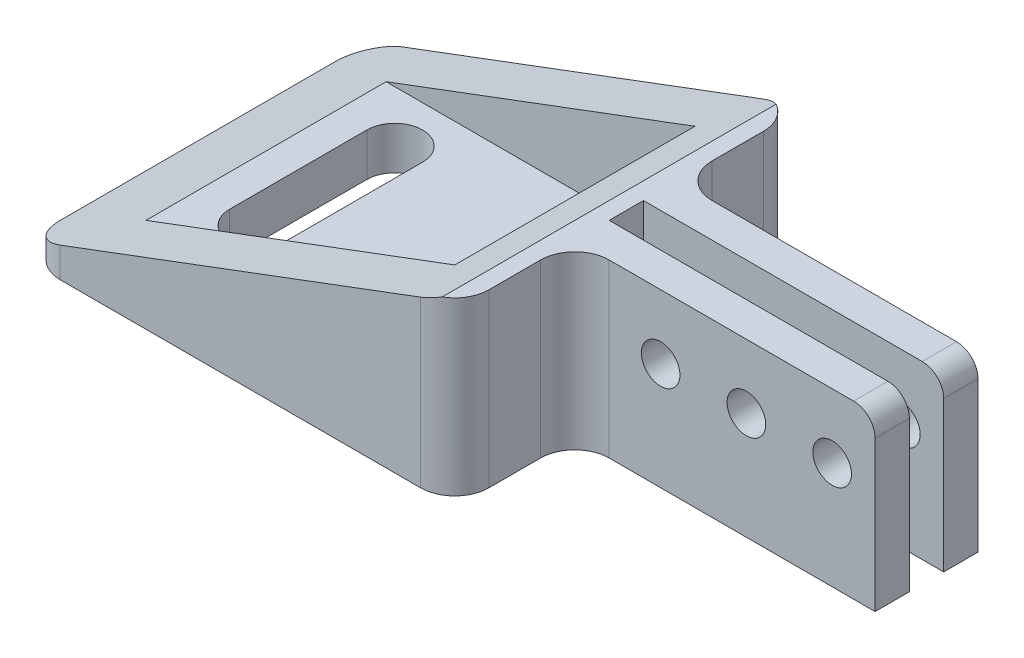
from build123d import *

# Parameters (mm, degrees)
SKETCH1_W               = 50
SKETCH1_H               = 40
BOSS_EXTRUDE1_DEPTH     = 20
BOSS_EXTRUDE2_START     = -20
SKETCH3_W               = 35
SKETCH3_H               = 4
BOSS_EXTRUDE2_DEPTH     = 20
SKETCH4_R               = 2.25
CUT_EXTRUDE1_DEPTH      = 5
LPATTERN1_COUNT         = 3
LPATTERN1_PITCH         = 10
MIRROR1_COPY_1_SKETCH_R = 2.25
MIRROR1_COPY_1_DEPTH    = 5
MIRROR1_COPY_2_SKETCH_R = 2.25
MIRROR1_COPY_2_DEPTH    = 5
CUT_EXTRUDE2_DEPTH      = 75.833147735
CUT_EXTRUDE2_DEPTH_BACK = 75.833147735
SKETCH6_W               = 38
SKETCH6_H               = 28
CUT_EXTRUDE3_DEPTH      = 15
CUT_EXTRUDE4_DEPTH      = 66
FILLET1_R               = 2.5
FILLET2_R               = 4
FILLET3_R               = 4


with BuildPart() as part:
    # Sketch1 → Boss-Extrude1 (new body)
    with BuildSketch(Plane(origin=(0, 0, 0), x_dir=(1, 0, 0), z_dir=(0, 1, 0))):
        Rectangle(SKETCH1_W, SKETCH1_H)
    extrude(amount=BOSS_EXTRUDE1_DEPTH)

    # Sketch3 → Boss-Extrude2 (add)
    with BuildSketch(Plane(origin=(0, 20, 0), x_dir=(1, 0, 0), z_dir=(0, 1, 0)).offset(BOSS_EXTRUDE2_START)):
        with Locations((42.5, -4)):
            Rectangle(SKETCH3_W, SKETCH3_H)
    boss_extrude2 = extrude(amount=BOSS_EXTRUDE2_DEPTH)

    # Sketch4 → Cut-Extrude1 (cut)
    with BuildSketch(Plane.XY.offset(6)):
        with Locations((55, 12.5)):
            Circle(SKETCH4_R)
    cut_extrude1 = extrude(amount=-CUT_EXTRUDE1_DEPTH, mode=Mode.SUBTRACT)

    # LPattern1: Cut-Extrude1 ×3
    with Locations(*[(-i * LPATTERN1_PITCH, 0, 0) for i in range(1, LPATTERN1_COUNT)]):
        add(cut_extrude1, mode=Mode.SUBTRACT)

    # Mirror1: Boss-Extrude2, Cut-Extrude1 across plane
    add(boss_extrude2.mirror(Plane.XY))
    add(cut_extrude1.mirror(Plane.XY), mode=Mode.SUBTRACT)

    # Mirror1 copy 1 sketch → Mirror1 copy 1 (cut)
    with BuildSketch(Plane(origin=(-10, 0, -6), x_dir=(1, 0, 0), z_dir=(0, 0, -1))):
        with Locations((55, -12.5)):
            Circle(MIRROR1_COPY_1_SKETCH_R)
    extrude(amount=-MIRROR1_COPY_1_DEPTH, mode=Mode.SUBTRACT)

    # Mirror1 copy 2 sketch → Mirror1 copy 2 (cut)
    with BuildSketch(Plane(origin=(-20, 0, -6), x_dir=(1, 0, 0), z_dir=(0, 0, -1))):
        with Locations((55, -12.5)):
            Circle(MIRROR1_COPY_2_SKETCH_R)
    extrude(amount=-MIRROR1_COPY_2_DEPTH, mode=Mode.SUBTRACT)

    # Sketch5 → Cut-Extrude2 (cut, two sides)
    with BuildSketch(Plane.XY.offset(20)) as cut_extrude2_sk:
        Polygon((23, 20), (-25, 2), (-25, 20), align=None)
    extrude(amount=CUT_EXTRUDE2_DEPTH, mode=Mode.SUBTRACT)
    extrude(cut_extrude2_sk.sketch, amount=-CUT_EXTRUDE2_DEPTH_BACK, mode=Mode.SUBTRACT)

    # Sketch6 → Cut-Extrude3 (cut)
    with BuildSketch(Plane(origin=(0, 20, 0), x_dir=(1, 0, 0), z_dir=(0, 1, 0))):
        Rectangle(SKETCH6_W, SKETCH6_H)
    extrude(amount=-CUT_EXTRUDE3_DEPTH, mode=Mode.SUBTRACT)

    # Sketch7 → Cut-Extrude4 (cut, symmetric)
    with BuildSketch(Plane(origin=(0, 5, 0), x_dir=(1, 0, 0), z_dir=(0, 1, 0))):
        with BuildLine():
            Line((13.25, 8), (13.25, -8))
            ThreePointArc((13.25, -8), (10, -11.25), (6.75, -8))
            Line((6.75, -8), (6.75, 8))
            ThreePointArc((6.75, 8), (10, 11.25), (13.25, 8))
        make_face()
    cut_extrude4 = extrude(amount=CUT_EXTRUDE4_DEPTH, both=True, mode=Mode.SUBTRACT)

    # Mirror2: Cut-Extrude4 across plane
    add(cut_extrude4.mirror(Plane(origin=(0, 0, 0), x_dir=(0, 0, 1), z_dir=(1, 0, 0))), mode=Mode.SUBTRACT)

    # Fillet1
    fillet1_edges = [part.edges().sort_by_distance(p)[0] for p in [
        (60, 20, 4),
        (60, 20, -4),
    ]]
    fillet(fillet1_edges, radius=FILLET1_R)

    # Fillet2
    fillet2_edges = [part.edges().sort_by_distance(p)[0] for p in [
        (25, 10, 6),
        (25, 10, -6),
    ]]
    fillet(fillet2_edges, radius=FILLET2_R)

    # Fillet3
    fillet3_edges = [part.edges().sort_by_distance(p)[0] for p in [
        (-25, 1, -20),
        (-25, 1, 20),
        (25, 10, -20),
        (25, 10, 20),
    ]]
    fillet(fillet3_edges, radius=FILLET3_R)


solid = part.part
